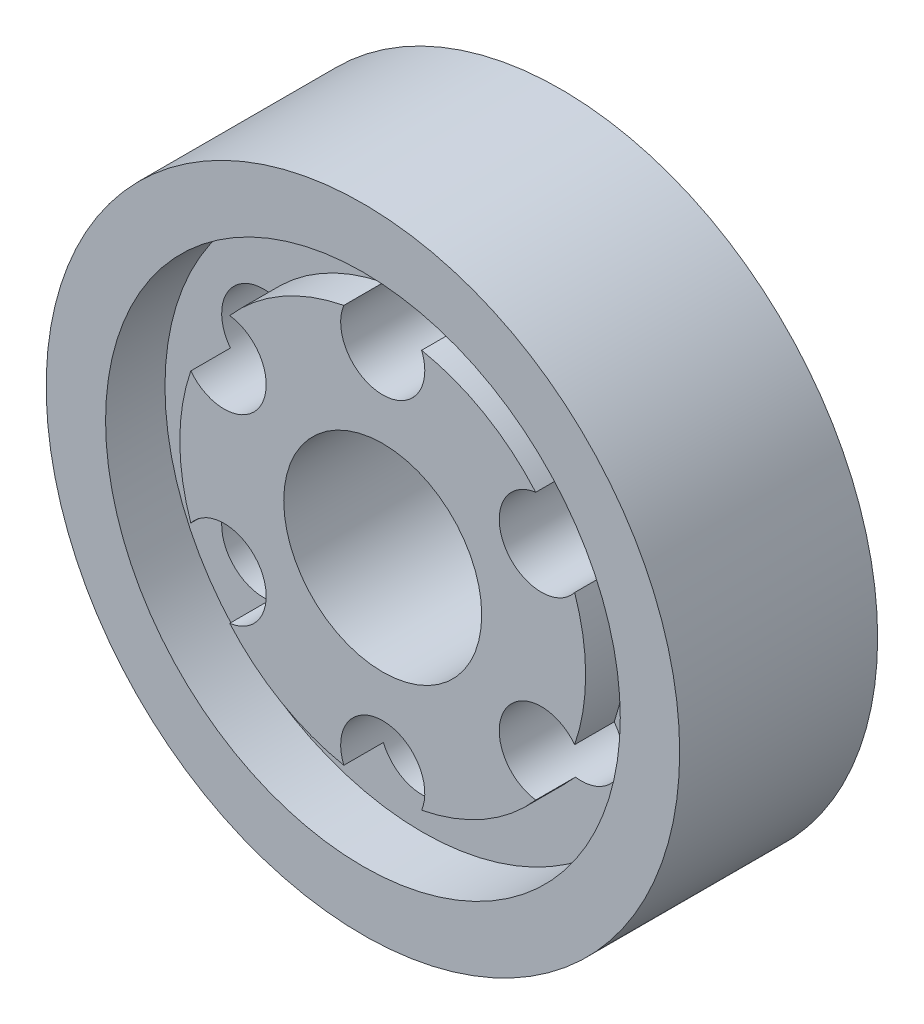
from build123d import *

# Parameters (mm, degrees)
SKETCH1_R           = 32
BOSS_EXTRUDE1_DEPTH = 20
SKETCH2_R           = 26
CUT_EXTRUDE1_DEPTH  = 6
SKETCH3_R           = 20.5
BOSS_EXTRUDE2_DEPTH = 4
SKETCH4_R           = 10
CUT_EXTRUDE2_DEPTH  = 82
SKETCH5_R           = 4.25
CUT_EXTRUDE3_DEPTH  = 19
CIRPATTERN1_COUNT   = 6


with BuildPart() as part:
    # Sketch1 → Boss-Extrude1 (new body)
    with BuildSketch(Plane.XY):
        Circle(SKETCH1_R)
    extrude(amount=BOSS_EXTRUDE1_DEPTH)

    # Sketch2 → Cut-Extrude1 (cut)
    with BuildSketch(Plane.XY.offset(20)):
        Circle(SKETCH2_R)
    extrude(amount=-CUT_EXTRUDE1_DEPTH, mode=Mode.SUBTRACT)

    # Sketch3 → Boss-Extrude2 (add)
    with BuildSketch(Plane.XY.offset(14)):
        Circle(SKETCH3_R)
    extrude(amount=BOSS_EXTRUDE2_DEPTH)

    # Sketch4 → Cut-Extrude2 (cut)
    with BuildSketch(Plane.XY.offset(18)):
        Circle(SKETCH4_R)
    extrude(amount=-CUT_EXTRUDE2_DEPTH, mode=Mode.SUBTRACT)

    # Sketch5 → Cut-Extrude3 (cut, through all)
    with BuildSketch(Plane.XY.offset(18)):
        with Locations((0, 18.5)):
            Circle(SKETCH5_R)
    cut_extrude3 = extrude(amount=-CUT_EXTRUDE3_DEPTH, mode=Mode.SUBTRACT)

    # CirPattern1: Cut-Extrude3 ×6 about axis
    cirpattern1_axis = Axis((0, 0, 0), (0, 0, 1))
    for i in range(1, CIRPATTERN1_COUNT):
        add(cut_extrude3.rotate(cirpattern1_axis, i * 360 / CIRPATTERN1_COUNT), mode=Mode.SUBTRACT)


solid = part.part
